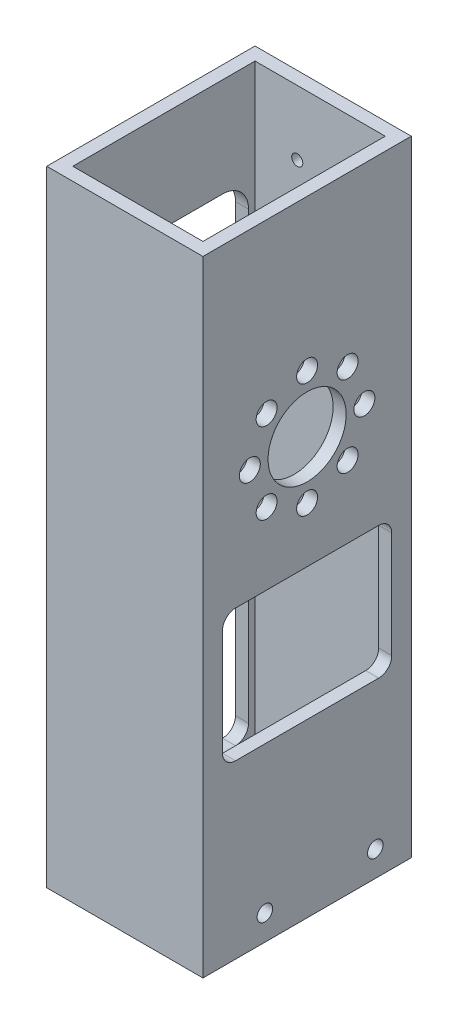
from build123d import *

# Parameters (mm, degrees)
SKETCH1_W                      = 38.1
SKETCH1_H                      = 50.8
SKETCH1_W_2                    = 31.75
SKETCH1_H_2                    = 44.45
BOSS_EXTRUDE1_DEPTH            = 152.4
SKETCH2_R                      = 1.89865
CUT_EXTRUDE1_DEPTH             = 35.925
CUT_EXTRUDE1_DEPTH_BACK        = 4.175
CUT_EXTRUDE3_DEPTH             = 3.175
CUT_EXTRUDE4_DEPTH             = 3.175
SKETCH6_R                      = 9.525
SKETCH6_R_2                    = 2.5527
CUT_EXTRUDE5_DEPTH             = 3.175
CUT_EXTRUDE6_DEPTH             = 3.175
F_6_32_TAPPED_HOLE2_D          = 2.7051
F_6_32_TAPPED_HOLE2_DEPTH      = 3.175
CUT_EXTRUDE7_REACH             = 40.1
CUT_EXTRUDE7_DIRECTION_2_DEPTH = 1
FILLET1_R                      = 3.175
FILLET2_R                      = 3.175
BOSS_EXTRUDE2_DEPTH            = 3.175
CUT_EXTRUDE8_REACH             = 40.1
FILLET3_R                      = 3.175
FILLET4_R                      = 3.175
FILLET5_R                      = 6.35
FILLET6_R                      = 6.35
BOSS_EXTRUDE3_DEPTH            = 3.175
CUT_EXTRUDE9_REACH             = 40.1
BOSS_EXTRUDE4_DEPTH            = 3.175
FILLET7_R                      = 3.175
FILLET8_R                      = 3.175
FILLET9_R                      = 3.175
FILLET10_R                     = 3.175
FILLET11_R                     = 6.35
FILLET12_R                     = 6.35


with BuildPart() as part:
    # Sketch1 → Boss-Extrude1 (new body)
    with BuildSketch(Plane(origin=(0, 0, 0), x_dir=(1, 0, 0), z_dir=(0, 1, 0))):
        Rectangle(SKETCH1_W, SKETCH1_H)
        Rectangle(SKETCH1_W_2, SKETCH1_H_2, mode=Mode.SUBTRACT)
    extrude(amount=BOSS_EXTRUDE1_DEPTH)

    # Sketch2 → Cut-Extrude1 (cut, two sides)
    with BuildSketch(Plane.ZY.offset(-15.875)) as cut_extrude1_sk:
        with Locations((-16.645384182, 6.21538)):
            Circle(SKETCH2_R)
        with Locations((10.30030417, 6.18241423)):
            Circle(SKETCH2_R)
    extrude(amount=CUT_EXTRUDE1_DEPTH, mode=Mode.SUBTRACT)
    extrude(cut_extrude1_sk.sketch, amount=-CUT_EXTRUDE1_DEPTH_BACK, mode=Mode.SUBTRACT)

    # Sketch4 → Cut-Extrude3 (cut)
    with BuildSketch(Plane.ZY.offset(19.05)):
        with BuildLine():
            Line((17.4625, 10.16), (-17.4625, 10.16))
            ThreePointArc((-17.4625, 10.16), (-19.70756403, 11.08993597), (-20.6375, 13.335))
            Line((-20.6375, 13.335), (-20.6375, 64.135))
            ThreePointArc((-20.6375, 64.135), (-19.70756403, 66.38006403), (-17.4625, 67.31))
            Line((-17.4625, 67.31), (17.4625, 67.31))
            ThreePointArc((17.4625, 67.31), (19.70756403, 66.38006403), (20.6375, 64.135))
            Line((20.6375, 64.135), (20.6375, 13.335))
            ThreePointArc((20.6375, 13.335), (19.70756403, 11.08993597), (17.4625, 10.16))
        make_face()
    extrude(amount=-CUT_EXTRUDE3_DEPTH, mode=Mode.SUBTRACT)

    # Sketch5 → Cut-Extrude4 (cut)
    with BuildSketch(Plane(origin=(19.05, 0, 0), x_dir=(0, 0, -1), z_dir=(1, 0, 0))):
        with BuildLine():
            Line((17.4625, 67.31), (-17.4625, 67.31))
            ThreePointArc((-17.4625, 67.31), (-19.70756403, 66.38006403), (-20.6375, 64.135))
            Line((-20.6375, 64.135), (-20.6375, 45.085))
            ThreePointArc((-20.6375, 45.085), (-19.70756403, 42.83993597), (-17.4625, 41.91))
            Line((-17.4625, 41.91), (17.4625, 41.91))
            ThreePointArc((17.4625, 41.91), (19.70756403, 42.83993597), (20.6375, 45.085))
            Line((20.6375, 45.085), (20.6375, 64.135))
            ThreePointArc((20.6375, 64.135), (19.70756403, 66.38006403), (17.4625, 67.31))
        make_face()
    extrude(amount=-CUT_EXTRUDE4_DEPTH, mode=Mode.SUBTRACT)

    # Sketch6 → Cut-Extrude5 (cut)
    with BuildSketch(Plane.ZY.offset(-15.875)):
        with Locations((0, 101.6)):
            Circle(SKETCH6_R)
        with Locations((0, 87.63)):
            Circle(SKETCH6_R_2)
        with Locations((-9.878281733, 91.721718267)):
            Circle(SKETCH6_R_2)
        with Locations((-13.97, 101.6)):
            Circle(SKETCH6_R_2)
        with Locations((-9.878281733, 111.478281733)):
            Circle(SKETCH6_R_2)
        with Locations((0, 115.57)):
            Circle(SKETCH6_R_2)
        with Locations((9.878281733, 111.478281733)):
            Circle(SKETCH6_R_2)
        with Locations((13.97, 101.6)):
            Circle(SKETCH6_R_2)
        with Locations((9.878281733, 91.721718267)):
            Circle(SKETCH6_R_2)
    extrude(amount=-CUT_EXTRUDE5_DEPTH, mode=Mode.SUBTRACT)

    # Sketch7 → Cut-Extrude6 (cut)
    with BuildSketch(Plane.ZY.offset(19.05)):
        with BuildLine():
            Line((-14.2875, 77.47), (14.2875, 77.47))
            ThreePointArc((14.2875, 77.47), (18.777628061, 79.329871939), (20.6375, 83.82))
            Line((20.6375, 83.82), (20.6375, 121.92))
            ThreePointArc((20.6375, 121.92), (18.777628061, 126.410128061), (14.2875, 128.27))
            Line((14.2875, 128.27), (-14.2875, 128.27))
            ThreePointArc((-14.2875, 128.27), (-18.777628061, 126.410128061), (-20.6375, 121.92))
            Line((-20.6375, 121.92), (-20.6375, 83.82))
            ThreePointArc((-20.6375, 83.82), (-18.777628061, 79.329871939), (-14.2875, 77.47))
        make_face()
    extrude(amount=-CUT_EXTRUDE6_DEPTH, mode=Mode.SUBTRACT)

    # #6-32 Tapped Hole2
    with Locations(Plane(origin=(5.579615818, 136.6393, -25.4), x_dir=(-1, 0, 0), z_dir=(0, 0, -1))):
        with Locations((0, 0), (11.159231636, 0)):
            Hole(F_6_32_TAPPED_HOLE2_D / 2, depth=F_6_32_TAPPED_HOLE2_DEPTH)

    # Sketch13 → Cut-Extrude7 (cut, up to next)
    with BuildSketch(Plane(origin=(19.05, 0, 0), x_dir=(0, 0, -1), z_dir=(1, 0, 0)), mode=Mode.PRIVATE) as cut_extrude7_sk1:
        Polygon((0, 78.486), (20.6375, 78.486), (20.6375, 64.135), (-20.6375, 64.135), (-20.6375, 78.486), align=None)
    cut_extrude7_tool1 = extrude(cut_extrude7_sk1.sketch, amount=-CUT_EXTRUDE7_REACH, mode=Mode.PRIVATE) & part.part
    add(cut_extrude7_tool1.solids().sort_by_distance((19.05, 71.3105, 0))[0], mode=Mode.SUBTRACT)

    # Sketch13 → Cut-Extrude7 direction 2 (cut)
    with BuildSketch(Plane(origin=(19.05, 0, 0), x_dir=(0, 0, -1), z_dir=(1, 0, 0))):
        Polygon((0, 78.486), (20.6375, 78.486), (20.6375, 64.135), (-20.6375, 64.135), (-20.6375, 78.486), align=None)
    extrude(amount=CUT_EXTRUDE7_DIRECTION_2_DEPTH, mode=Mode.SUBTRACT)

    # Fillet1
    fillet1_edges = [part.edges().sort_by_distance(p)[0] for p in [
        (17.4625, 78.486, -20.6375),
    ]]
    fillet(fillet1_edges, radius=FILLET1_R)

    # Fillet2
    fillet2_edges = [part.edges().sort_by_distance(p)[0] for p in [
        (17.4625, 78.486, 20.6375),
    ]]
    fillet(fillet2_edges, radius=FILLET2_R)

    # Sketch15 → Boss-Extrude2 (add)
    with BuildSketch(Plane.ZY.offset(19.05)):
        Polygon((0, 78.486), (-20.6375, 78.486), (-20.6375, 88.646), (0, 88.646), (20.6375, 88.646), (20.6375, 78.486), align=None)
    extrude(amount=-BOSS_EXTRUDE2_DEPTH)

    # Sketch16 → Cut-Extrude8 (cut, up to next)
    with BuildSketch(Plane.ZY.offset(19.05), mode=Mode.PRIVATE) as cut_extrude8_sk1:
        Polygon((0, 78.486), (20.6375, 78.486), (20.6375, 64.135), (-20.6375, 64.135), (-20.6375, 78.486), align=None)
    cut_extrude8_tool1 = extrude(cut_extrude8_sk1.sketch, amount=-CUT_EXTRUDE8_REACH, mode=Mode.PRIVATE) & part.part
    add(cut_extrude8_tool1.solids().sort_by_distance((-19.05, 71.3105, 0))[0], mode=Mode.SUBTRACT)

    # Fillet3
    fillet3_edges = [part.edges().sort_by_distance(p)[0] for p in [
        (-17.4625, 78.486, 20.6375),
    ]]
    fillet(fillet3_edges, radius=FILLET3_R)

    # Fillet4
    fillet4_edges = [part.edges().sort_by_distance(p)[0] for p in [
        (-17.4625, 78.486, -20.6375),
    ]]
    fillet(fillet4_edges, radius=FILLET4_R)

    # Fillet5
    fillet5_edges = [part.edges().sort_by_distance(p)[0] for p in [
        (-17.4625, 88.646, -20.6375),
    ]]
    fillet(fillet5_edges, radius=FILLET5_R)

    # Fillet6
    fillet6_edges = [part.edges().sort_by_distance(p)[0] for p in [
        (-17.4625, 88.646, 20.6375),
    ]]
    fillet(fillet6_edges, radius=FILLET6_R)

    # Sketch17 → Boss-Extrude3 (add)
    with BuildSketch(Plane.ZY.offset(19.05)):
        Polygon((0, 74.168), (20.6375, 74.168), (20.6375, 84.35471455), (-20.6375, 84.35471455), (-20.6375, 74.168), align=None)
    extrude(amount=-BOSS_EXTRUDE3_DEPTH)

    # Sketch18 → Cut-Extrude9 (cut, up to next)
    with BuildSketch(Plane.ZY.offset(19.05), mode=Mode.PRIVATE) as cut_extrude9_sk1:
        Polygon((0, 84.328), (-20.6375, 84.328), (-20.6375, 94.996), (20.6375, 94.996), (20.6375, 84.328), align=None)
    cut_extrude9_tool1 = extrude(cut_extrude9_sk1.sketch, amount=-CUT_EXTRUDE9_REACH, mode=Mode.PRIVATE) & part.part
    add(cut_extrude9_tool1.solids().sort_by_distance((-19.05, 89.662, 0))[0], mode=Mode.SUBTRACT)

    # Sketch19 → Boss-Extrude4 (add)
    with BuildSketch(Plane(origin=(19.05, 0, 0), x_dir=(0, 0, -1), z_dir=(1, 0, 0))):
        Polygon((0, 74.168), (20.6375, 74.168), (20.6375, 78.486), (-20.6375, 78.486), (-20.6375, 74.168), align=None)
    extrude(amount=-BOSS_EXTRUDE4_DEPTH)

    # Fillet7
    fillet7_edges = [part.edges().sort_by_distance(p)[0] for p in [
        (17.4625, 74.168, -20.6375),
    ]]
    fillet(fillet7_edges, radius=FILLET7_R)

    # Fillet8
    fillet8_edges = [part.edges().sort_by_distance(p)[0] for p in [
        (17.4625, 74.168, 20.6375),
    ]]
    fillet(fillet8_edges, radius=FILLET8_R)

    # Fillet9
    fillet9_edges = [part.edges().sort_by_distance(p)[0] for p in [
        (-17.4625, 74.168, 20.6375),
    ]]
    fillet(fillet9_edges, radius=FILLET9_R)

    # Fillet10
    fillet10_edges = [part.edges().sort_by_distance(p)[0] for p in [
        (-17.4625, 74.168, -20.6375),
    ]]
    fillet(fillet10_edges, radius=FILLET10_R)

    # Fillet11
    fillet11_edges = [part.edges().sort_by_distance(p)[0] for p in [
        (-17.4625, 84.328, -20.6375),
    ]]
    fillet(fillet11_edges, radius=FILLET11_R)

    # Fillet12
    fillet12_edges = [part.edges().sort_by_distance(p)[0] for p in [
        (-17.4625, 84.328, 20.6375),
    ]]
    fillet(fillet12_edges, radius=FILLET12_R)


solid = part.part
